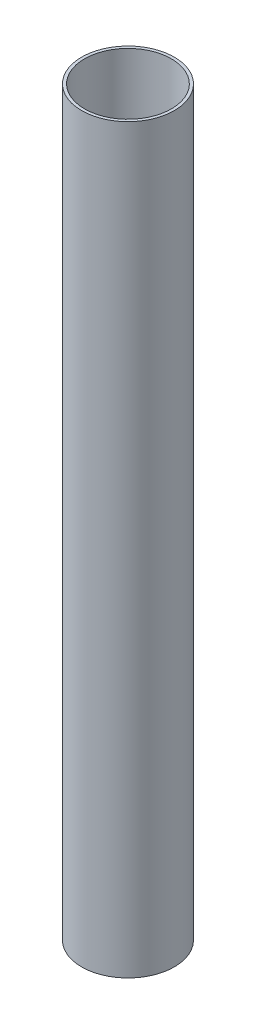
from build123d import *

# Parameters (mm, degrees)
SKETCH1_R   = 6.35
SKETCH1_R_2 = 5.94951949


with BuildPart() as part:
    # Sweep1: sweep along a path in Sketch2
    with BuildLine(Plane(origin=(0, 0, 0), x_dir=(0, 0, -1), z_dir=(1, 0, 0))) as sweep1_path:
        Line((0, 0), (0, 101.6))
    # Sketch1 → Sweep1 (sweep)
    with BuildSketch(Plane(origin=(0, 0, 0), x_dir=(1, 0, 0), z_dir=(0, 1, 0))):
        Circle(SKETCH1_R)
        Circle(SKETCH1_R_2, mode=Mode.SUBTRACT)
    sweep(path=sweep1_path.line)


solid = part.part
